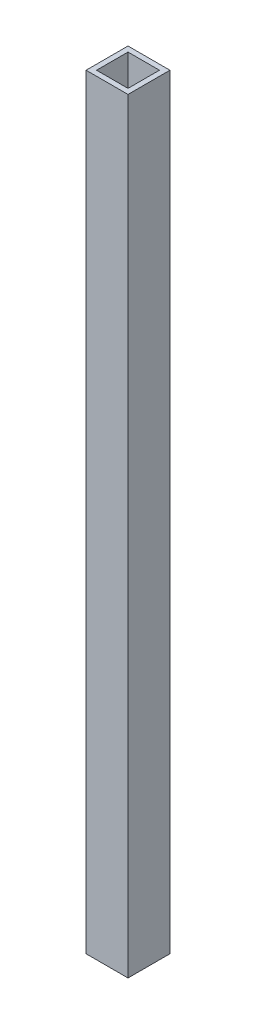
from build123d import *

# Parameters (mm, degrees)
SKETCH1_W           = 50.8
SKETCH1_H           = 50.8
SKETCH1_W_2         = 38.1
SKETCH1_H_2         = 38.1
BOSS_EXTRUDE1_DEPTH = 463.55


with BuildPart() as part:
    # Sketch1 → Boss-Extrude1 (new body, symmetric)
    with BuildSketch(Plane(origin=(0, 0, 0), x_dir=(1, 0, 0), z_dir=(0, 1, 0))):
        Rectangle(SKETCH1_W, SKETCH1_H)
        Rectangle(SKETCH1_W_2, SKETCH1_H_2, mode=Mode.SUBTRACT)
    extrude(amount=BOSS_EXTRUDE1_DEPTH, both=True)


solid = part.part
